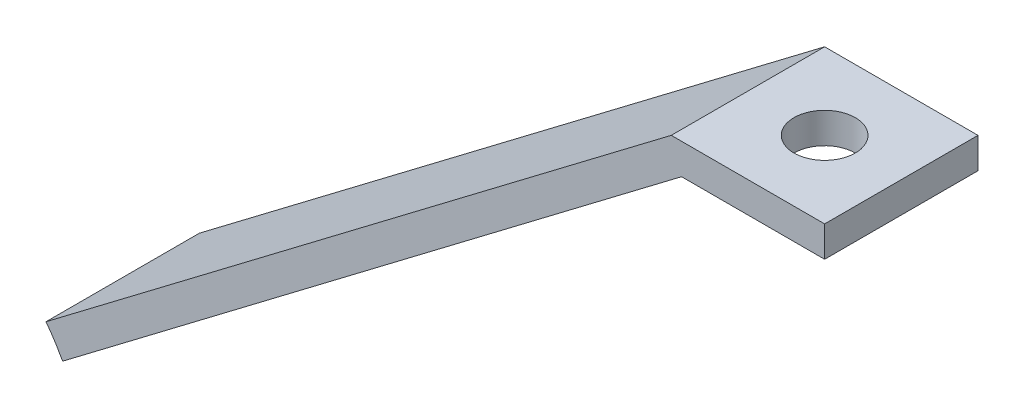
from build123d import *

# Parameters (mm, degrees)
DODANIE_WYCI_GNI_CIE1_DEPTH = 10
SZKIC2_R                    = 2
WYTNIJ_WYCI_GNI_CIE1_DEPTH  = 10


with BuildPart() as part:
    # Szkic1 → Dodanie-wyciągnięcie1 (new body)
    with BuildSketch(Plane(origin=(0, 0, 502.999346089), x_dir=(-1, 0, 0), z_dir=(0, 0, -1))):
        with BuildLine():
            Line((-929.814034739, -322.668005597), (-970.58269303, -291.759349877))
            Line((-970.58269303, -291.759349877), (-980.58269303, -291.759349877))
            Line((-980.58269303, -291.759349877), (-980.58269303, -293.759349877))
            Line((-980.58269303, -293.759349877), (-971.255135855, -293.759349877))
            Line((-971.255135855, -293.759349877), (-930.899175905, -324.355119388))
            add(Edge.make_bspline(
                [(-929.814034739, -322.668005597), (-930.214433706, -323.196133667), (-930.577577349, -323.759219062), (-930.899175905, -324.355119388)],
                knots=[0.163263648, 0.163263648, 0.163263648, 0.163263648, 0.18460997, 0.18460997, 0.18460997, 0.18460997], degree=3, weights=[0.560185558, 0.55031088, 0.54165131, 0.534206848]))
        make_face()
    extrude(amount=DODANIE_WYCI_GNI_CIE1_DEPTH)

    # Szkic2 → Wytnij-wyciągnięcie1 (cut)
    with BuildSketch(Plane(origin=(0, -293.759349877, 0), x_dir=(-1, 0, 0), z_dir=(0, -1, 0))):
        with Locations((-975.58269303, -497.999346089)):
            Circle(SZKIC2_R)
    extrude(amount=-WYTNIJ_WYCI_GNI_CIE1_DEPTH, mode=Mode.SUBTRACT)


solid = part.part
